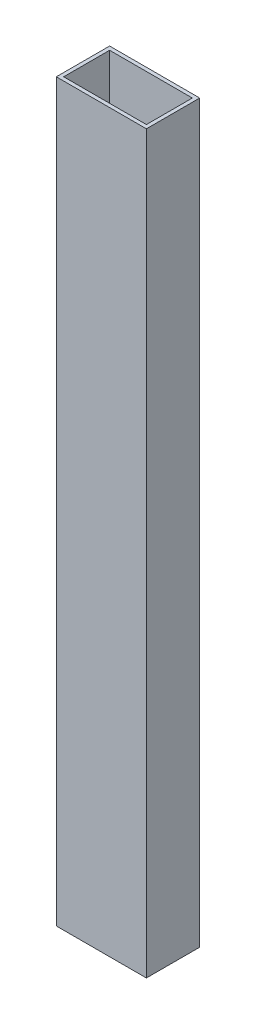
from build123d import *

# Parameters (mm, degrees)
CROQUIS2_W              = 49
CROQUIS2_H              = 29
CROQUIS2_W_2            = 45
CROQUIS2_H_2            = 25
SALIENTE_EXTRUIR2_DEPTH = 200


with BuildPart() as part:
    # Croquis2 → Saliente-Extruir2 (new body, symmetric)
    with BuildSketch(Plane(origin=(0, 0, 0), x_dir=(1, 0, 0), z_dir=(0, 1, 0))):
        Rectangle(CROQUIS2_W, CROQUIS2_H)
        Rectangle(CROQUIS2_W_2, CROQUIS2_H_2, mode=Mode.SUBTRACT)
    extrude(amount=SALIENTE_EXTRUIR2_DEPTH, both=True)


solid = part.part
